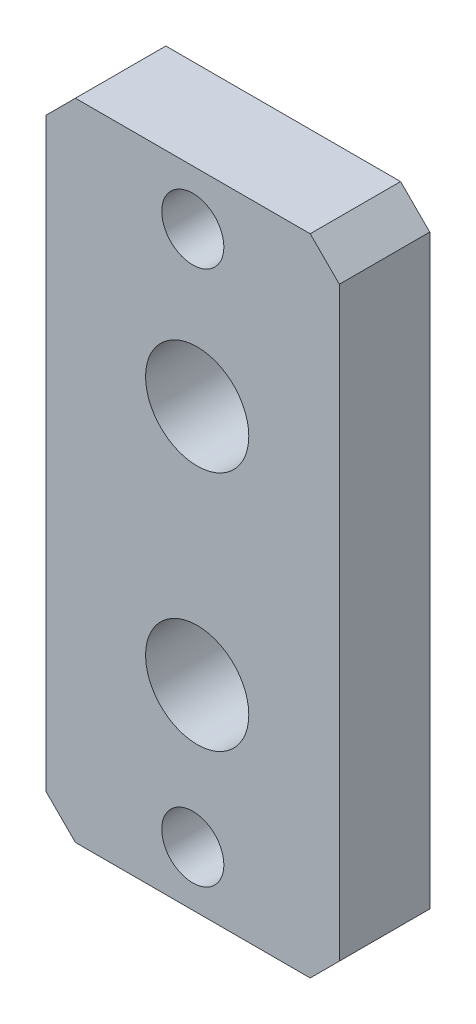
from build123d import *

# Parameters (mm, degrees)
SKETCH1_W                                         = 12.7635
SKETCH1_H                                         = 28.067000578
BOSS_EXTRUDE1_DEPTH                               = 0.762
SKETCH3_W                                         = 12.7635
SKETCH3_H                                         = 28.067000578
BOSS_EXTRUDE2_DEPTH                               = 3.175
CSK_FOR_2_FLAT_HEAD_MACHINE_SCREW_100_D           = 2.7051
CSK_FOR_2_FLAT_HEAD_MACHINE_SCREW_100_DEPTH       = 3.937
CSK_FOR_2_FLAT_HEAD_MACHINE_SCREW_100_CSINK_D     = 4.3688
CSK_FOR_2_FLAT_HEAD_MACHINE_SCREW_100_CSINK_ANGLE = 100
F_16_0_177_DIAMETER_HOLE1_D                       = 4.4958
F_16_0_177_DIAMETER_HOLE1_DEPTH                   = 3.175
CHAMFER1_SIZE                                     = 1.27


with BuildPart() as part:
    # Sketch1 → Boss-Extrude1 (new body)
    with BuildSketch(Plane.XY):
        with Locations((-14.669644351, 41.878697202)):
            Rectangle(SKETCH1_W, SKETCH1_H)
        with BuildLine():
            Line((-9.049894351, 33.115696913), (-9.049894351, 50.641696913))
            ThreePointArc((-9.049894351, 50.641696913), (-9.198684106, 51.000907158), (-9.557894351, 51.149696913))
            Line((-9.557894351, 51.149696913), (-19.781394351, 51.149696913))
            ThreePointArc((-19.781394351, 51.149696913), (-20.140604596, 51.000907158), (-20.289394351, 50.641696913))
            Line((-20.289394351, 50.641696913), (-20.289394351, 33.115696913))
            ThreePointArc((-20.289394351, 33.115696913), (-20.140604596, 32.756486668), (-19.781394351, 32.607696913))
            Line((-19.781394351, 32.607696913), (-9.557894351, 32.607696913))
            ThreePointArc((-9.557894351, 32.607696913), (-9.198684106, 32.756486668), (-9.049894351, 33.115696913))
        make_face(mode=Mode.SUBTRACT)
    extrude(amount=-BOSS_EXTRUDE1_DEPTH)

    # Sketch3 → Boss-Extrude2 (add)
    with BuildSketch(Plane.XY):
        with Locations((-14.669644351, 41.878697202)):
            Rectangle(SKETCH3_W, SKETCH3_H)
    extrude(amount=BOSS_EXTRUDE2_DEPTH)

    # CSK for #2 Flat Head Machine Screw (100)1
    with Locations(Plane(origin=(0, 0, -0.762), x_dir=(-1, 0, 0), z_dir=(0, 0, -1))):
        with Locations((14.669644351, 53.530947491), (14.669644351, 30.226446913)):
            CounterSinkHole(CSK_FOR_2_FLAT_HEAD_MACHINE_SCREW_100_D / 2, CSK_FOR_2_FLAT_HEAD_MACHINE_SCREW_100_CSINK_D / 2, depth=CSK_FOR_2_FLAT_HEAD_MACHINE_SCREW_100_DEPTH, counter_sink_angle=CSK_FOR_2_FLAT_HEAD_MACHINE_SCREW_100_CSINK_ANGLE)

    # #16 (0.177) Diameter Hole1
    with Locations(Plane(origin=(0, 0, 0), x_dir=(-1, 0, 0), z_dir=(0, 0, -1))):
        with Locations((14.479144351, 36.436086129), (14.479144351, 46.940307697)):
            Hole(F_16_0_177_DIAMETER_HOLE1_D / 2, depth=F_16_0_177_DIAMETER_HOLE1_DEPTH)

    # Chamfer1
    chamfer1_edges = [part.edges().sort_by_distance(p)[0] for p in [
        (-8.287894351, 27.845196913, 1.2065),
        (-21.051394351, 27.845196913, 1.2065),
        (-21.051394351, 55.912197491, 1.2065),
        (-8.287894351, 55.912197491, 1.2065),
    ]]
    chamfer(chamfer1_edges, length=CHAMFER1_SIZE)


solid = part.part
